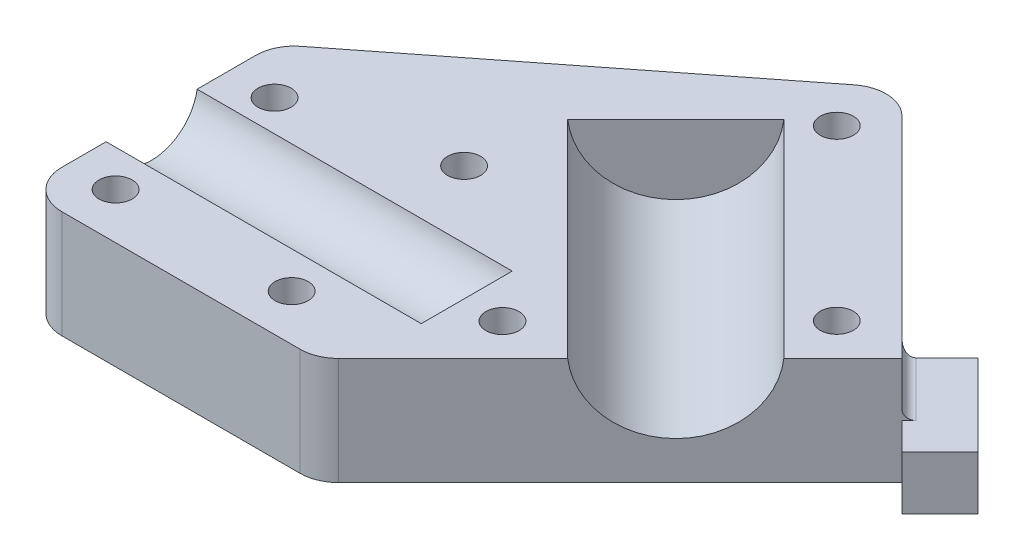
from build123d import *

# Parameters (mm, degrees)
EXTRUDE_1_DEPTH        = 14
EXTRUDE_2_DEPTH        = 7
CUT_EXTRUDE_1_DEPTH    = 41.028932
CUT_EXTRUDE_2_DEPTH    = 38.1
HOLE_WIZARD_M4_1_D     = 4.318
HOLE_WIZARD_M4_1_DEPTH = 14
FILLET_1_R             = 5
FILLET_3_R             = 1.27
FILLET_4_R             = 1.27


with BuildPart() as part:
    # 草图1 → 凸台-拉伸1 (new body)
    with BuildSketch(Plane.XZ.offset(15)):
        Polygon((4.743453, -52.27499), (35.219756, -21.798688), (-2.928932, 16.35), (-41.028932, 16.35), (-41.028932, -16.35), align=None)
    extrude(amount=-EXTRUDE_1_DEPTH)

    # 草图2 → 凸台-拉伸2 (add)
    with BuildSketch(Plane.XZ.offset(15)):
        Polygon((43.705037, -23.212901), (38.75529, -18.263154), (35.219756, -21.798688), (28.148688, -28.869756), (33.098435, -33.819503), align=None)
    extrude(amount=-EXTRUDE_2_DEPTH)

    # 草图3 → 切除-拉伸1 (cut)
    with BuildSketch(Plane.ZY.offset(41.028932)):
        with BuildLine():
            Line((5.5795, -1), (-6.270766, -1))
            ThreePointArc((-6.270766, -1), (-0.345633, -6.055118), (5.5795, -1))
        make_face()
    extrude(amount=-CUT_EXTRUDE_1_DEPTH, mode=Mode.SUBTRACT)

    # 草图4 → 切除-拉伸2 (cut)
    with BuildSketch(Plane(origin=(6.710534, 0, 6.710534), x_dir=(0.707107, 0, -0.707107), z_dir=(0.707107, 0, 0.707107))):
        with BuildLine():
            Line((29.445831, -1), (9.538252, -1))
            ThreePointArc((9.538252, -1), (19.492041, -10.039754), (29.445831, -1))
        make_face()
    extrude(amount=-CUT_EXTRUDE_2_DEPTH, mode=Mode.SUBTRACT)

    # M4 间隙孔1
    with Locations(Plane(origin=(0, -15, 0), x_dir=(-1, 0, 0), z_dir=(0, -1, 0))):
        with Locations((35.028932, -10.35), (-5, 0), (15, 15), (12.103043, -10.35), (35.028932, 10.35), (-4.743453, 43.789709), (-26.734474, 21.798688)):
            Hole(HOLE_WIZARD_M4_1_D / 2, depth=HOLE_WIZARD_M4_1_DEPTH)

    # 圆角1
    fillet_1_edges = [part.edges().sort_by_distance(p)[0] for p in [
        (-41.028932, -8, -16.35),
        (-41.028932, -8, 16.35),
        (-2.928932, -8, 16.35),
        (4.743453, -8, -52.27499),
    ]]
    fillet(fillet_1_edges, radius=FILLET_1_R)

    # 圆角3
    fillet_3_edges = [part.edges().sort_by_distance(p)[0] for p in [
        (31.684222, -8, -25.334222),
    ]]
    fillet(fillet_3_edges, radius=FILLET_3_R)

    # 圆角4
    fillet_4_edges = [part.edges().sort_by_distance(p)[0] for p in [
        (28.148688, -11.5, -28.869756),
    ]]
    fillet(fillet_4_edges, radius=FILLET_4_R)


solid = part.part
